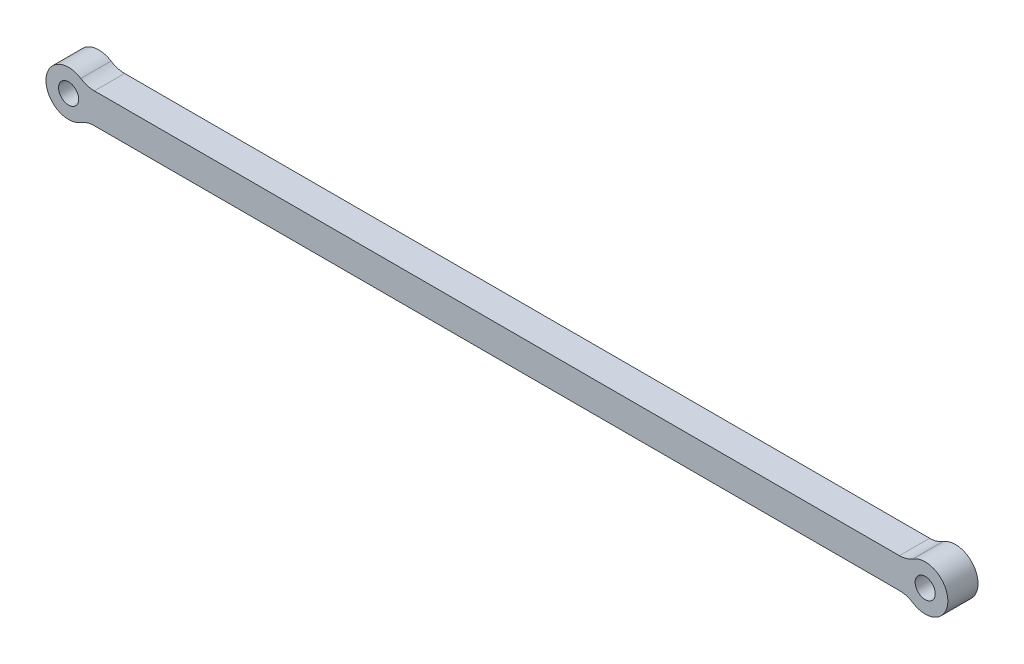
from build123d import *

# Parameters (mm, degrees)
SKETCH1_R           = 4
BOSS_EXTRUDE1_DEPTH = 12
FILLET1_R           = 10


with BuildPart() as part:
    # Sketch1 → Boss-Extrude1 (new body)
    with BuildSketch(Plane.XY):
        with BuildLine():
            Line((333.691896068, 6), (6.708203932, 6))
            ThreePointArc((6.708203932, 6), (-9, 0), (6.708203932, -6))
            Line((6.708203932, -6), (333.691896068, -6))
            ThreePointArc((333.691896068, -6), (349.4001, 0), (333.691896068, 6))
        make_face()
        Circle(SKETCH1_R, mode=Mode.SUBTRACT)
        with Locations((340.4001, 0)):
            Circle(SKETCH1_R, mode=Mode.SUBTRACT)
    extrude(amount=BOSS_EXTRUDE1_DEPTH)

    # Fillet1
    fillet1_edges = [part.edges().sort_by_distance(p)[0] for p in [
        (6.708203932, 6, 6),
        (333.691896068, 6, 6),
        (333.691896068, -6, 6),
        (6.708203932, -6, 6),
    ]]
    fillet(fillet1_edges, radius=FILLET1_R)


solid = part.part
